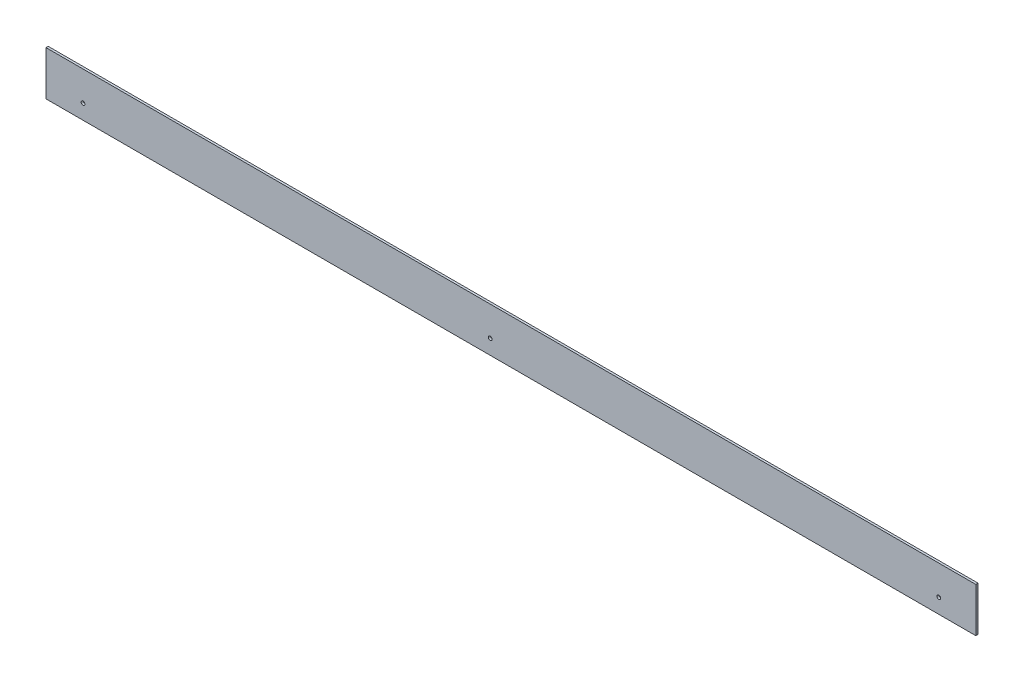
from build123d import *

# Parameters (mm, degrees)
SKETCH1_W           = 1256
SKETCH1_H           = 60
SKETCH1_R           = 2.55
BOSS_EXTRUDE1_DEPTH = 3


with BuildPart() as part:
    # Sketch1 → Boss-Extrude1 (new body)
    with BuildSketch(Plane.XY):
        Rectangle(SKETCH1_W, SKETCH1_H)
        with Locations((-28, -10)):
            Circle(SKETCH1_R, mode=Mode.SUBTRACT)
        with Locations((578, -10)):
            Circle(SKETCH1_R, mode=Mode.SUBTRACT)
        with Locations((-578, -10)):
            Circle(SKETCH1_R, mode=Mode.SUBTRACT)
    extrude(amount=BOSS_EXTRUDE1_DEPTH)


solid = part.part
